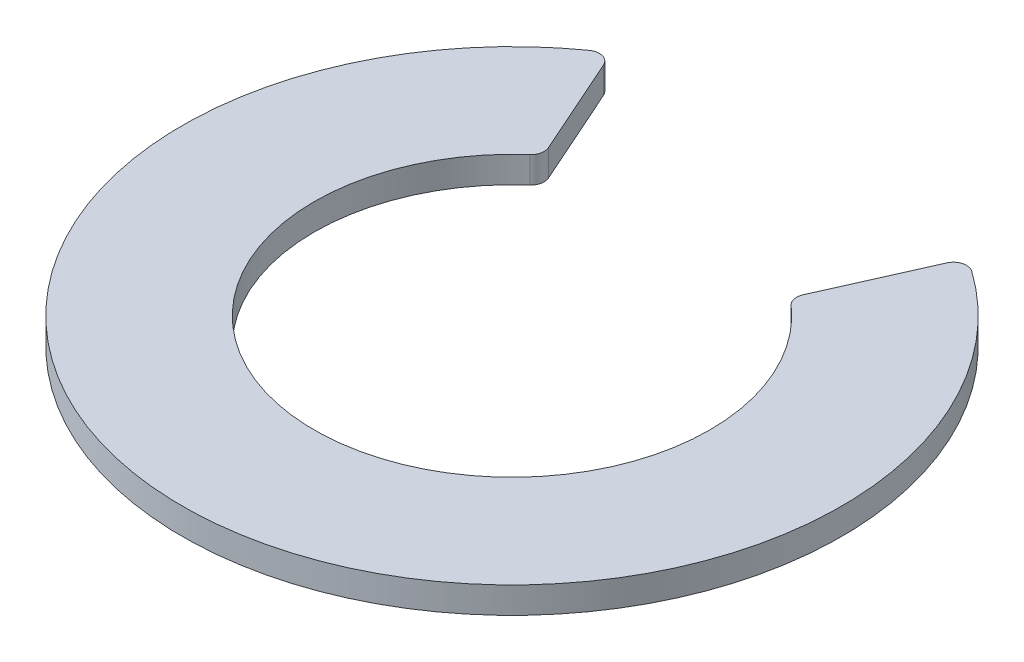
from build123d import *

# Parameters (mm, degrees)
BOSS_EXTRUDE1_DEPTH = 2


with BuildPart() as part:
    # Sketch1 → Boss-Extrude1 (new body)
    with BuildSketch(Plane(origin=(0, 0, 0), x_dir=(1, 0, 0), z_dir=(0, 1, 0))):
        with BuildLine():
            Line((-13.009739648, 19.954523886), (-9.658322262, 12.415843118))
            ThreePointArc((-9.658322262, 12.415843118), (-9.595186414, 11.795950439), (-9.911337799, 11.259013413))
            ThreePointArc((-9.911337799, 11.259013413), (0, -15), (9.911337799, 11.259013413))
            ThreePointArc((9.911337799, 11.259013413), (9.595186414, 11.795950439), (9.658322262, 12.415843118))
            Line((9.658322262, 12.415843118), (13.009739648, 19.954523886))
            ThreePointArc((13.009739648, 19.954523886), (13.659881986, 20.512919211), (14.503657332, 20.36280737))
            ThreePointArc((14.503657332, 20.36280737), (0, -25), (-14.503657332, 20.36280737))
            ThreePointArc((-14.503657332, 20.36280737), (-13.659881986, 20.512919211), (-13.009739648, 19.954523886))
        make_face()
    extrude(amount=BOSS_EXTRUDE1_DEPTH)


solid = part.part
